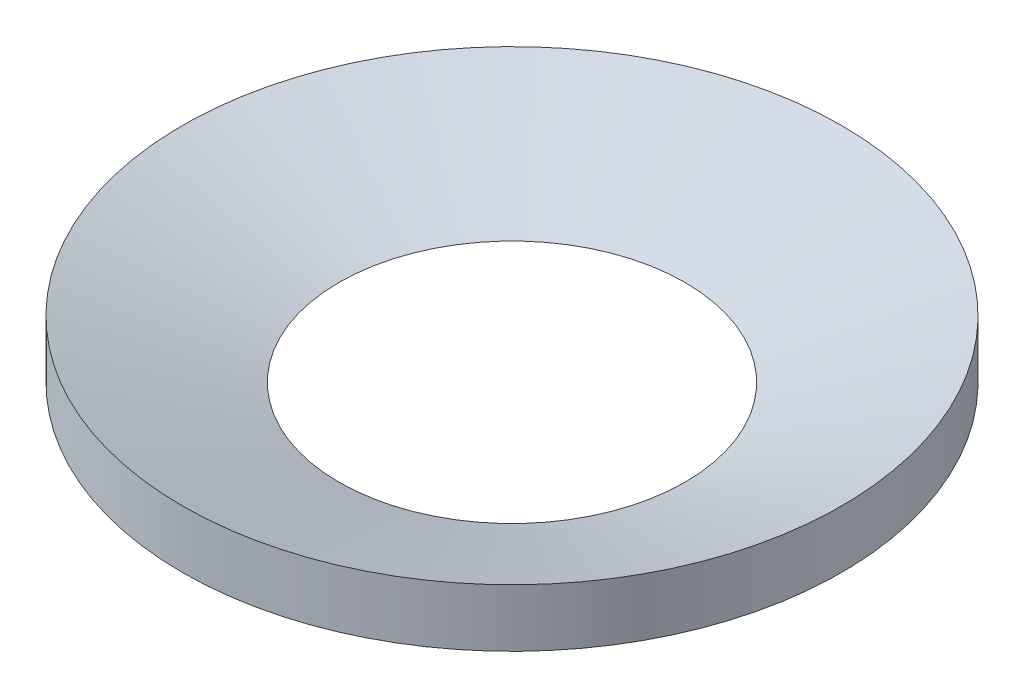
from build123d import *


with BuildPart() as part:
    # Sketch1 → Revolve1 (revolve)
    with BuildSketch(Plane.XY):
        Polygon((10.5, 0), (20, 0), (20, 3.5), align=None)
    revolve(axis=Axis((0, 0, 0), (0, 1, 0)))


solid = part.part
